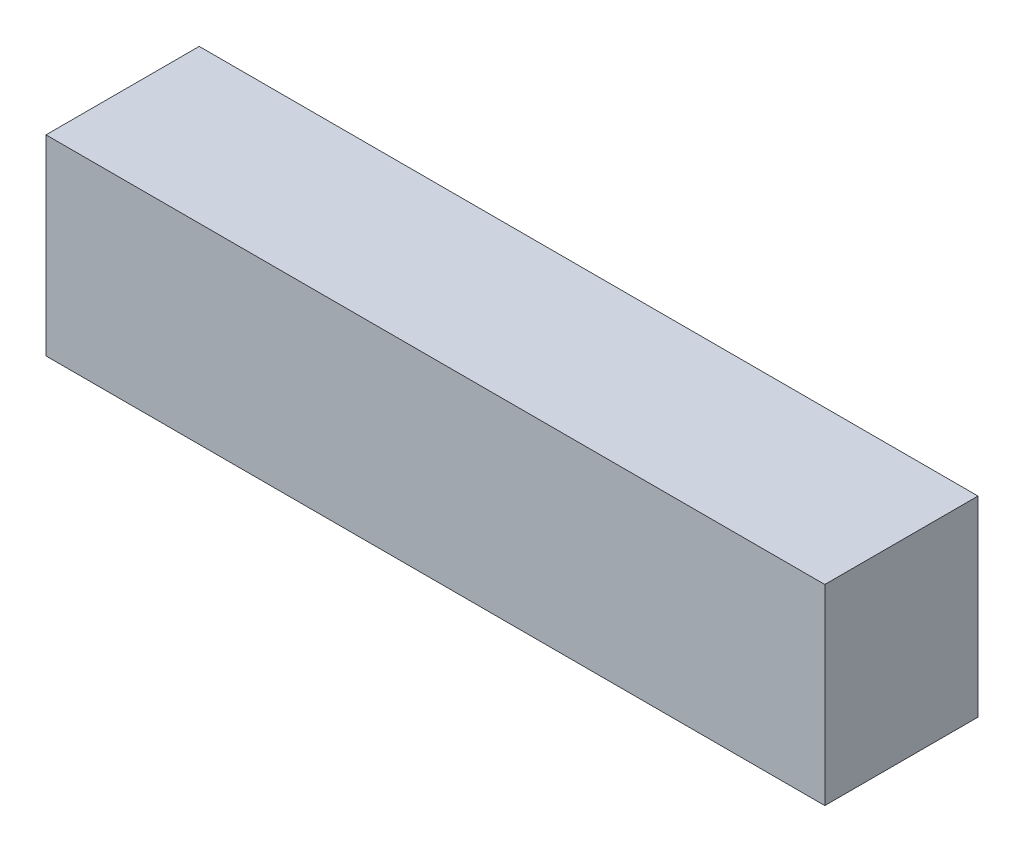
from build123d import *

# Parameters (mm, degrees)
SKETCH1_W           = 61
SKETCH1_H           = 15
BOSS_EXTRUDE1_DEPTH = 12


with BuildPart() as part:
    # Sketch1 → Boss-Extrude1 (new body)
    with BuildSketch(Plane.XY):
        with Locations((30.5, -7.5)):
            Rectangle(SKETCH1_W, SKETCH1_H)
    extrude(amount=BOSS_EXTRUDE1_DEPTH)


solid = part.part
